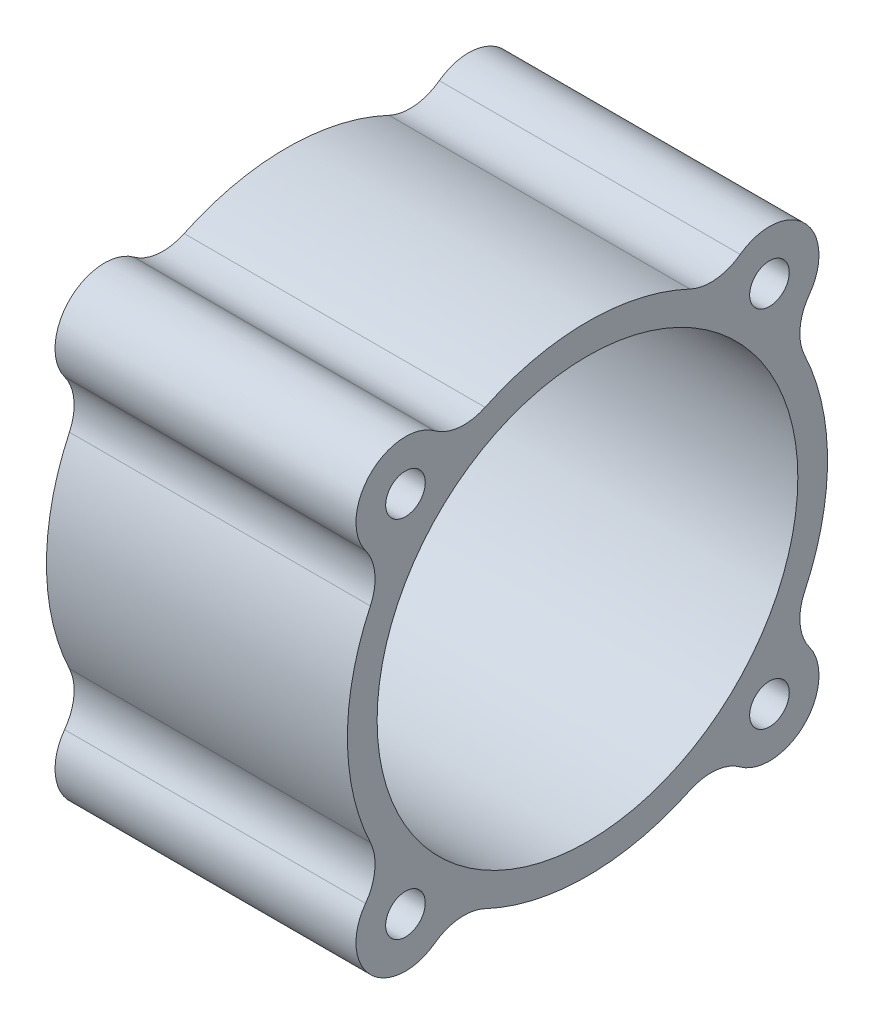
from build123d import *

# Parameters (mm, degrees)
SKETCH_1_R      = 21.25
SKETCH_1_R_2    = 2
EXTRUDE_1_DEPTH = 15.2


with BuildPart() as part:
    # 草图1 → 凸台-拉伸1 (new body, symmetric)
    with BuildSketch(Plane(origin=(0, 0, 0), x_dir=(0, 0, -1), z_dir=(1, 0, 0))):
        with BuildLine():
            ThreePointArc((-15.431825442, 22.419634577), (-21.920310245, 21.920310245), (-22.419634577, 15.431825442))
            ThreePointArc((-22.419634577, 15.431825442), (-21.477282941, 12.955720303), (-21.932357291, 10.345733597))
            ThreePointArc((-21.932357291, 10.345733597), (-24.25, 0), (-21.932357291, -10.345733597))
            ThreePointArc((-21.932357291, -10.345733597), (-21.477282941, -12.955720303), (-22.419634577, -15.431825442))
            ThreePointArc((-22.419634577, -15.431825442), (-21.920310245, -21.920310245), (-15.431825442, -22.419634577))
            ThreePointArc((-15.431825442, -22.419634577), (-12.955720303, -21.477282941), (-10.345733597, -21.932357291))
            ThreePointArc((-10.345733597, -21.932357291), (0, -24.25), (10.345733597, -21.932357291))
            ThreePointArc((10.345733597, -21.932357291), (12.955720303, -21.477282941), (15.431825442, -22.419634577))
            ThreePointArc((15.431825442, -22.419634577), (21.920310245, -21.920310245), (22.419634577, -15.431825442))
            ThreePointArc((22.419634577, -15.431825442), (21.477282941, -12.955720303), (21.932357291, -10.345733597))
            ThreePointArc((21.932357291, -10.345733597), (24.25, 0), (21.932357291, 10.345733597))
            ThreePointArc((21.932357291, 10.345733597), (21.477282941, 12.955720303), (22.419634577, 15.431825442))
            ThreePointArc((22.419634577, 15.431825442), (21.920310245, 21.920310245), (15.431825442, 22.419634577))
            ThreePointArc((15.431825442, 22.419634577), (12.955720303, 21.477282941), (10.345733597, 21.932357291))
            ThreePointArc((10.345733597, 21.932357291), (0, 24.25), (-10.345733597, 21.932357291))
            ThreePointArc((-10.345733597, 21.932357291), (-12.955720303, 21.477282941), (-15.431825442, 22.419634577))
        make_face()
        Circle(SKETCH_1_R, mode=Mode.SUBTRACT)
        with Locations((-18.384776339, 18.384776339)):
            Circle(SKETCH_1_R_2, mode=Mode.SUBTRACT)
        with Locations((18.384776339, 18.384776339)):
            Circle(SKETCH_1_R_2, mode=Mode.SUBTRACT)
        with Locations((18.384776339, -18.384776339)):
            Circle(SKETCH_1_R_2, mode=Mode.SUBTRACT)
        with Locations((-18.384776339, -18.384776339)):
            Circle(SKETCH_1_R_2, mode=Mode.SUBTRACT)
    extrude(amount=EXTRUDE_1_DEPTH, both=True)


solid = part.part
